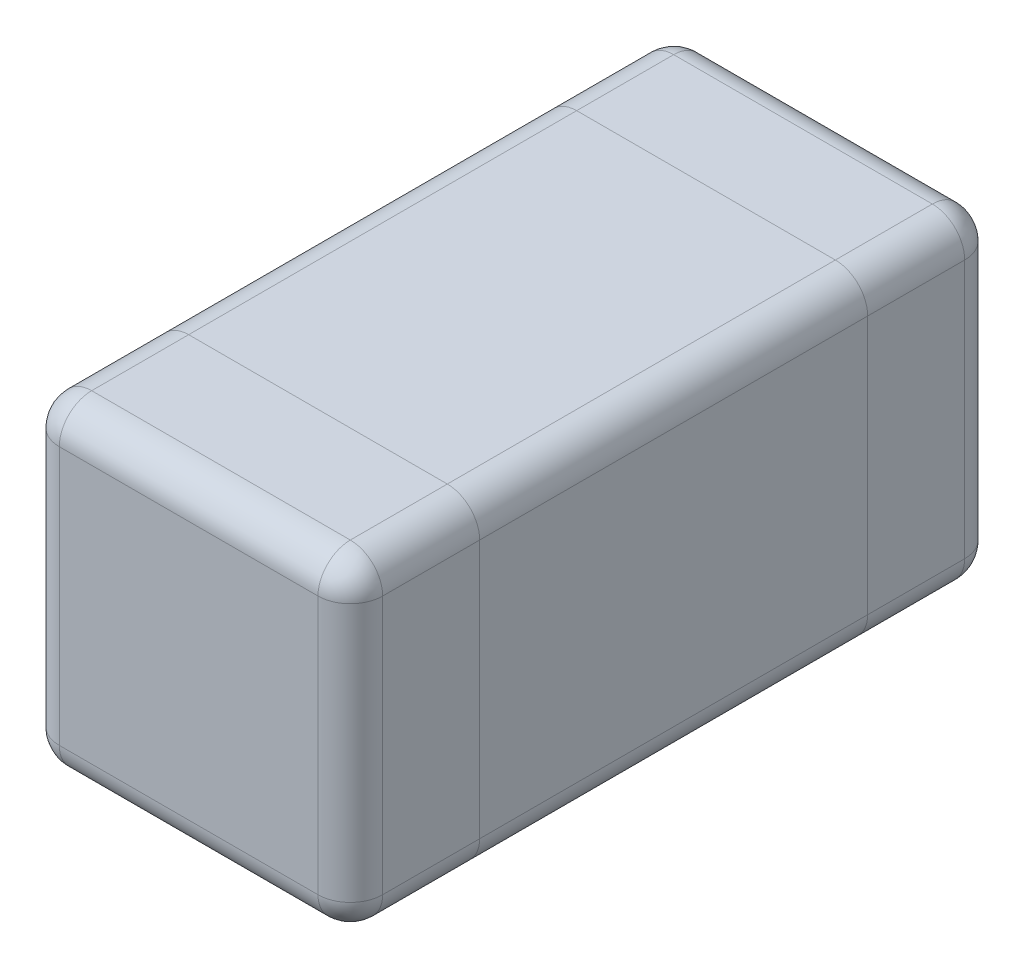
from build123d import *

# Parameters (mm, degrees)
SKETCH2_W           = 0.5
SKETCH2_H           = 0.5
BOSS_EXTRUDE1_DEPTH = 0.2
SKETCH3_W           = 0.5
SKETCH3_H           = 0.5
BOSS_EXTRUDE2_DEPTH = 0.6
SKETCH5_W           = 0.5
SKETCH5_H           = 0.5
BOSS_EXTRUDE4_DEPTH = 0.2
FILLET2_R           = 0.05
FILLET3_R           = 0.05
FILLET4_R           = 0.05


with BuildPart() as part:
    # Sketch2 → Boss-Extrude1 (new body)
    with BuildSketch(Plane.XY):
        with Locations((0.25, 0.25)):
            Rectangle(SKETCH2_W, SKETCH2_H)
    extrude(amount=BOSS_EXTRUDE1_DEPTH)

    # Fillet4
    fillet4_edges = [part.edges().sort_by_distance(p)[0] for p in [
        (0.25, 0.5, 0),
        (0.5, 0.25, 0),
        (0.25, 0, 0),
        (0, 0.25, 0),
        (0, 0.5, 0.1),
        (0.5, 0.5, 0.1),
        (0.5, 0, 0.1),
        (0, 0, 0.1),
    ]]
    fillet(fillet4_edges, radius=FILLET4_R)


with BuildPart() as body_2:
    # Sketch3 → Boss-Extrude2 (new body)
    with BuildSketch(Plane.XY.offset(0.2)):
        with Locations((0.25, 0.25)):
            Rectangle(SKETCH3_W, SKETCH3_H)
    extrude(amount=BOSS_EXTRUDE2_DEPTH)

    # Fillet3
    fillet3_edges = [body_2.edges().sort_by_distance(p)[0] for p in [
        (0.5, 0.5, 0.5),
        (0.5, 0, 0.5),
        (0, 0, 0.5),
        (0, 0.5, 0.5),
    ]]
    fillet(fillet3_edges, radius=FILLET3_R)


with BuildPart() as body_3:
    # Sketch5 → Boss-Extrude4 (new body)
    with BuildSketch(Plane.XY.offset(0.8)):
        with Locations((0.25, 0.25)):
            Rectangle(SKETCH5_W, SKETCH5_H)
    extrude(amount=BOSS_EXTRUDE4_DEPTH)

    # Fillet2
    fillet2_edges = [body_3.edges().sort_by_distance(p)[0] for p in [
        (0, 0.25, 1),
        (0.25, 0, 1),
        (0.5, 0.25, 1),
        (0.25, 0.5, 1),
        (0.5, 0, 0.9),
        (0, 0, 0.9),
        (0, 0.5, 0.9),
        (0.5, 0.5, 0.9),
    ]]
    fillet(fillet2_edges, radius=FILLET2_R)


solid = Compound([part.part, body_2.part, body_3.part])
